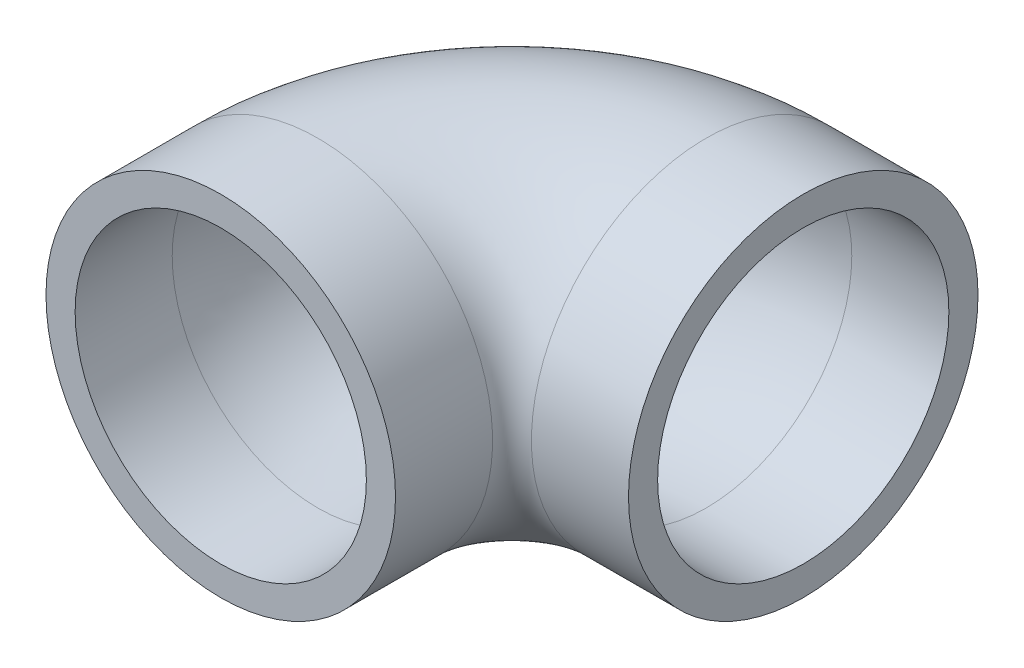
from build123d import *

# Parameters (mm, degrees)
SKETCH1_R   = 22.86
SKETCH1_R_2 = 19.05


with BuildPart() as part:
    # Sweep1: sweep along a path in Sketch3
    with BuildLine(Plane(origin=(0, 0, 0), x_dir=(1, 0, 0), z_dir=(0, 1, 0))) as sweep1_path:
        Line((0, 0), (0, 12.7))
        ThreePointArc((0, 12.7), (7.439487758, 30.660512242), (25.4, 38.1))
        Line((25.4, 38.1), (38.1, 38.1))
    # Sketch1 → Sweep1 (sweep)
    with BuildSketch(Plane.XY):
        Circle(SKETCH1_R)
        Circle(SKETCH1_R_2, mode=Mode.SUBTRACT)
    sweep(path=sweep1_path.line)


solid = part.part
